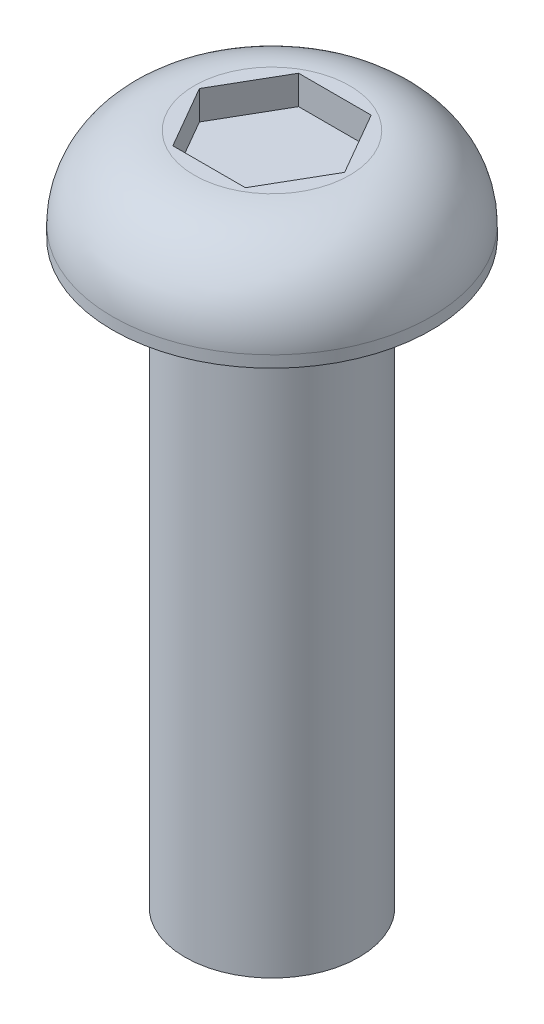
from build123d import *

# Parameters (mm, degrees)
CUT_EXTRUDE1_DEPTH = 0.5


with BuildPart() as part:
    # Sketch1 → Revolve1 (revolve)
    with BuildSketch(Plane.XY):
        with BuildLine():
            Line((0, 1.61), (1.34, 1.61))
            ThreePointArc((1.34, 1.61), (2.337020561, 1.197020561), (2.75, 0.2))
            Line((2.75, 0.2), (2.75, 0))
            Line((2.75, 0), (1.5, 0))
            Line((1.5, 0), (1.5, -10))
            Line((1.5, -10), (0, -10))
            Line((0, -10), (0, 1.61))
        make_face()
    revolve(axis=Axis((0, 9.083769969, 0), (0, -1, 0)))

    # Sketch2 → Cut-Extrude1 (cut)
    with BuildSketch(Plane(origin=(0, 1.61, 0), x_dir=(1, 0, 0), z_dir=(0, 1, 0))):
        Polygon((0.62654248, 1.085203409), (-0.62654248, 1.085203409), (-1.253084961, 0), (-0.62654248, -1.085203409), (0.62654248, -1.085203409), (1.253084961, 0), align=None)
    extrude(amount=-CUT_EXTRUDE1_DEPTH, mode=Mode.SUBTRACT)


solid = part.part
